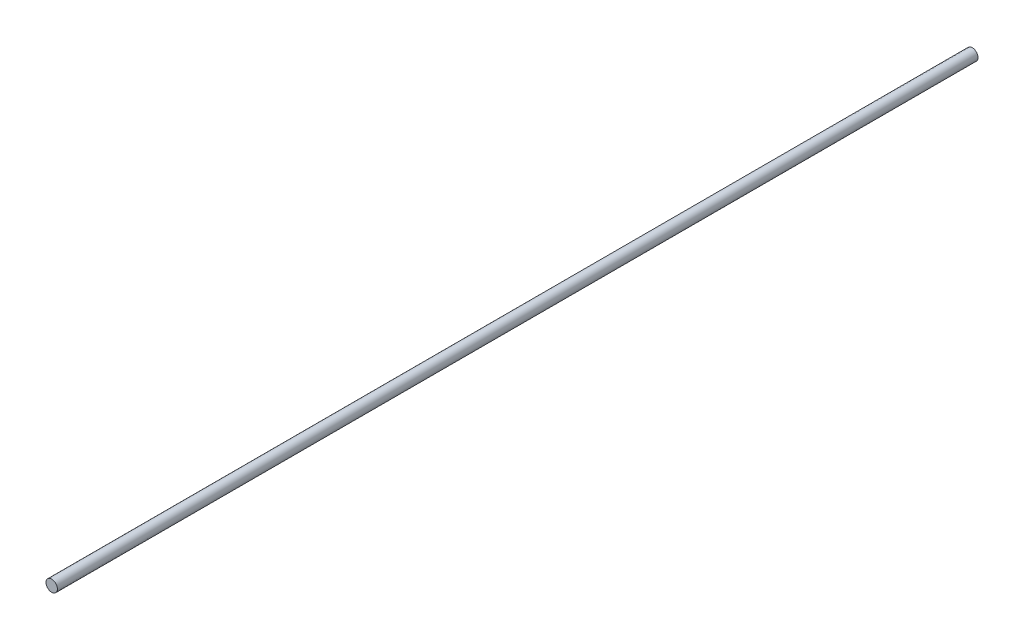
from build123d import *

# Parameters (mm, degrees)
SKETCH_1_R      = 4
EXTRUDE_1_DEPTH = 645


with BuildPart() as part:
    # 草图1 → 凸台-拉伸1 (new body)
    with BuildSketch(Plane.XY):
        Circle(SKETCH_1_R)
    extrude(amount=EXTRUDE_1_DEPTH)


solid = part.part
